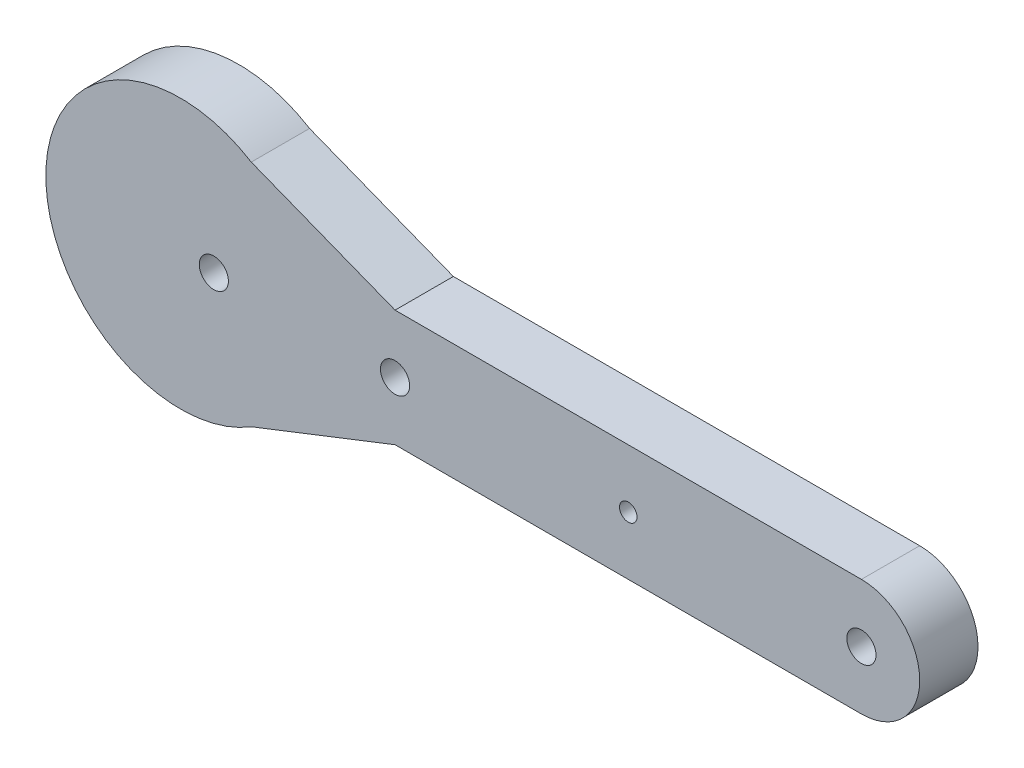
from build123d import *

# Parameters (mm, degrees)
ESQUISSE1_R        = 2.5
ESQUISSE1_R_2      = 1.5
BOSS_EXTRU_1_DEPTH = 10


with BuildPart() as part:
    # Esquisse1 → Boss.-Extru.1 (new body)
    with BuildSketch(Plane.XY):
        with BuildLine():
            Line((0, 0), (80, 0))
            ThreePointArc((80, 0), (90, 10), (80, 20))
            Line((80, 20), (0, 20))
            Line((0, 20), (-24.667286758, 29.658401944))
            ThreePointArc((-24.667286758, 29.658401944), (-59.912850456, 10), (-24.667286758, -9.658401944))
            Line((-24.667286758, -9.658401944), (0, 0))
        make_face()
        with Locations((0, 10)):
            Circle(ESQUISSE1_R, mode=Mode.SUBTRACT)
        with Locations((80, 10)):
            Circle(ESQUISSE1_R, mode=Mode.SUBTRACT)
        with Locations((-31.091119471, 10)):
            Circle(ESQUISSE1_R, mode=Mode.SUBTRACT)
        with Locations((40, 10)):
            Circle(ESQUISSE1_R_2, mode=Mode.SUBTRACT)
    extrude(amount=BOSS_EXTRU_1_DEPTH)


solid = part.part
